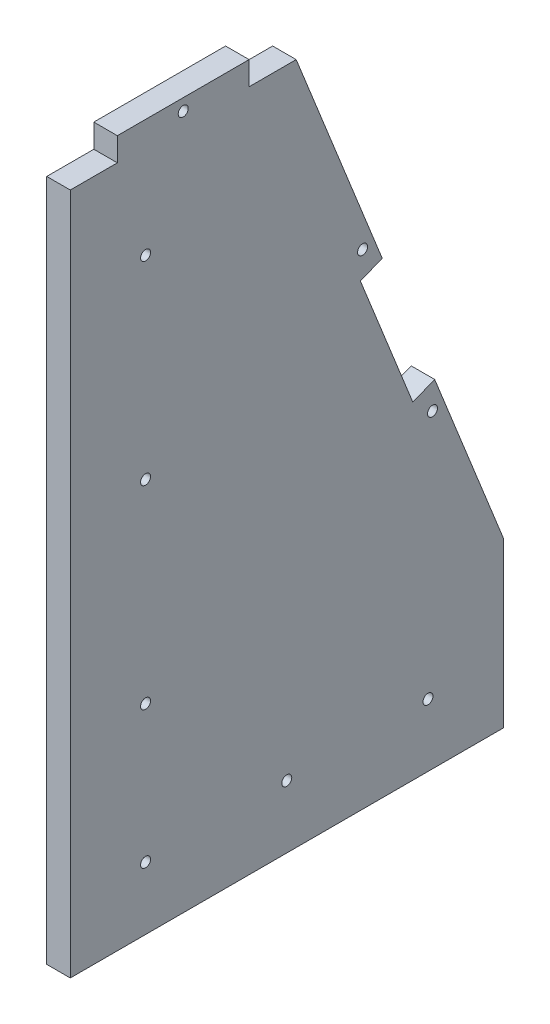
from build123d import *

# Parameters (mm, degrees)
SKETCH1_R           = 2.7
BOSS_EXTRUDE1_DEPTH = 12.7
TOP_HOLE_REACH      = 14.7
SKETCH3_R           = 2.7
SKETCH3_W           = 25.4
SKETCH3_H           = 12.7
BACK_HOLES_REACH    = 14.7
SKETCH4_R           = 2.7


with BuildPart() as part:
    # Sketch1 → Boss-Extrude1 (new body)
    with BuildSketch(Plane(origin=(0, 0, 0), x_dir=(0, -1, 0), z_dir=(-1, 0, 0))):
        Polygon((-381, 0), (-381, -116.84), (-88.9, -233.68), (0, -233.68), (0, 0), align=None)
        with Locations((-212.725, -40.64)):
            Circle(SKETCH1_R, mode=Mode.SUBTRACT)
        with Locations((-317.5, -40.64)):
            Circle(SKETCH1_R, mode=Mode.SUBTRACT)
        with Locations((-107.95, -40.64)):
            Circle(SKETCH1_R, mode=Mode.SUBTRACT)
        with Locations((-33.866666667, -193.04)):
            Circle(SKETCH1_R, mode=Mode.SUBTRACT)
        with Locations((-33.866666667, -40.64)):
            Circle(SKETCH1_R, mode=Mode.SUBTRACT)
        with Locations((-33.866666667, -116.84)):
            Circle(SKETCH1_R, mode=Mode.SUBTRACT)
    extrude(amount=-BOSS_EXTRUDE1_DEPTH)

    # Sketch3 → top hole (cut, up to next)
    with BuildSketch(Plane(origin=(12.7, 0, 0), x_dir=(0, 0, -1), z_dir=(1, 0, 0)), mode=Mode.PRIVATE) as top_hole_sk1:
        with Locations((60.96, 374.65)):
            Circle(SKETCH3_R)
    top_hole_tool1 = extrude(top_hole_sk1.sketch, amount=-TOP_HOLE_REACH, mode=Mode.PRIVATE) & part.part
    add(top_hole_tool1.solids().sort_by_distance((12.7, 374.65, -60.96))[0], mode=Mode.SUBTRACT)
    # Sketch3 → top hole (cut, up to next)
    with BuildSketch(Plane(origin=(12.7, 0, 0), x_dir=(0, 0, -1), z_dir=(1, 0, 0)), mode=Mode.PRIVATE) as top_hole_sk2:
        with Locations((12.7, 374.65)):
            Rectangle(SKETCH3_W, SKETCH3_H)
    top_hole_tool2 = extrude(top_hole_sk2.sketch, amount=-TOP_HOLE_REACH, mode=Mode.PRIVATE) & part.part
    add(top_hole_tool2.solids().sort_by_distance((12.7, 374.65, -12.7))[0], mode=Mode.SUBTRACT)
    # Sketch3 → top hole (cut, up to next)
    with BuildSketch(Plane(origin=(12.7, 0, 0), x_dir=(0, 0, -1), z_dir=(1, 0, 0)), mode=Mode.PRIVATE) as top_hole_sk3:
        with Locations((109.22, 374.65)):
            Rectangle(SKETCH3_W, SKETCH3_H)
    top_hole_tool3 = extrude(top_hole_sk3.sketch, amount=-TOP_HOLE_REACH, mode=Mode.PRIVATE) & part.part
    add(top_hole_tool3.solids().sort_by_distance((12.7, 374.65, -109.22))[0], mode=Mode.SUBTRACT)

    # Sketch4 → back holes (cut, up to next)
    with BuildSketch(Plane(origin=(12.7, 0, 0), x_dir=(0, 0, -1), z_dir=(1, 0, 0)), mode=Mode.PRIVATE) as back_holes_sk1:
        with Locations((157.754188244, 261.616631128)):
            Circle(SKETCH4_R)
    back_holes_tool1 = extrude(back_holes_sk1.sketch, amount=-BACK_HOLES_REACH, mode=Mode.PRIVATE) & part.part
    add(back_holes_tool1.solids().sort_by_distance((12.7, 261.616631, -157.754188))[0], mode=Mode.SUBTRACT)
    # Sketch4 → back holes (cut, up to next)
    with BuildSketch(Plane(origin=(12.7, 0, 0), x_dir=(0, 0, -1), z_dir=(1, 0, 0)), mode=Mode.PRIVATE) as back_holes_sk2:
        with Locations((195.487480961, 167.283399334)):
            Circle(SKETCH4_R)
    back_holes_tool2 = extrude(back_holes_sk2.sketch, amount=-BACK_HOLES_REACH, mode=Mode.PRIVATE) & part.part
    add(back_holes_tool2.solids().sort_by_distance((12.7, 167.283399, -195.487481))[0], mode=Mode.SUBTRACT)
    # Sketch4 → back holes (cut, up to next)
    with BuildSketch(Plane(origin=(12.7, 0, 0), x_dir=(0, 0, -1), z_dir=(1, 0, 0)), mode=Mode.PRIVATE) as back_holes_sk3:
        Polygon((156.575022846, 247.466646359), (184.874992385, 176.716722513), (196.666646359, 181.433384103), (168.366676821, 252.183307948), align=None)
    back_holes_tool3 = extrude(back_holes_sk3.sketch, amount=-BACK_HOLES_REACH, mode=Mode.PRIVATE) & part.part
    add(back_holes_tool3.solids().sort_by_distance((12.7, 214.450015, -176.620835))[0], mode=Mode.SUBTRACT)


solid = part.part
